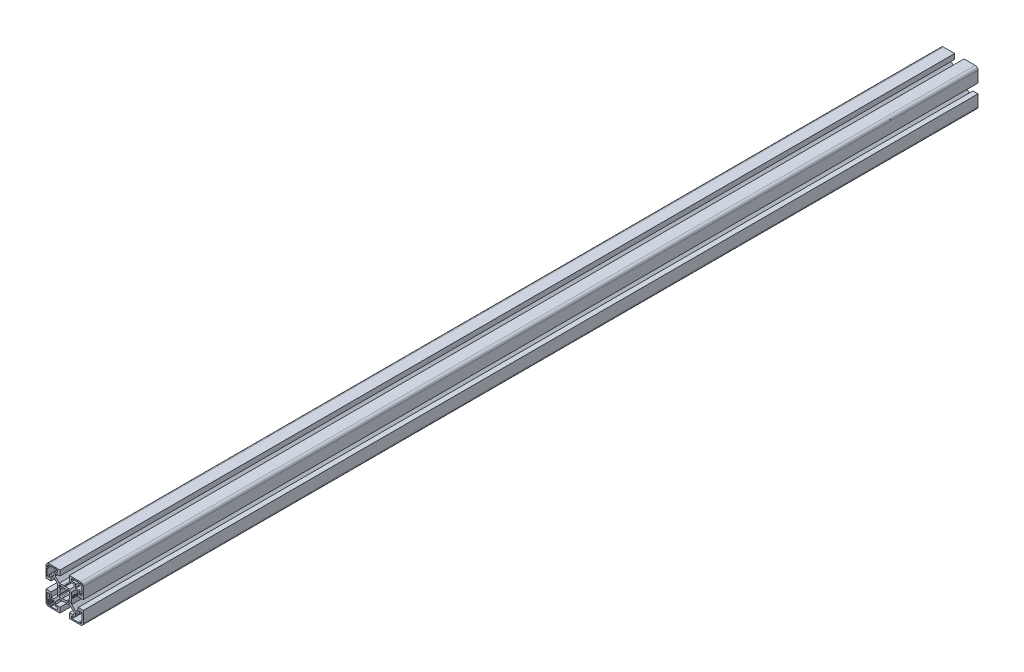
from build123d import *

# Parameters (mm, degrees)
BOSS_EXTRUDE1_DEPTH = 960


with BuildPart() as part:
    # Sketch1 → Boss-Extrude1 (new body)
    with BuildSketch(Plane.XY):
        with BuildLine():
            Line((-11.767766953, -10), (-14.5, -10))
            Line((-14.5, -10), (-14.5, -5))
            Line((-14.5, -5), (-20, -5))
            Line((-20, -5), (-20, -17))
            ThreePointArc((-20, -17), (-19.121320344, -19.121320344), (-17, -20))
            Line((-17, -20), (-5, -20))
            Line((-5, -20), (-5, -14.5))
            Line((-5, -14.5), (-10, -14.5))
            Line((-10, -14.5), (-10, -11.767766953))
            Line((-10, -11.767766953), (-5.732233047, -7.5))
            Line((-5.732233047, -7.5), (-0.653589838, -7.5))
            ThreePointArc((-0.653589838, -7.5), (-0.524180316, -7.482962913), (-0.403589838, -7.433012702))
            Line((-0.403589838, -7.433012702), (0, -7.2))
            Line((0, -7.2), (0.403589838, -7.433012702))
            ThreePointArc((0.403589838, -7.433012702), (0.653589838, -7.5), (0.903589838, -7.433012702))
            Line((0.903589838, -7.433012702), (1.218885629, -7.250976592))
            Line((1.218885629, -7.250976592), (2.5, -7.5))
            Line((2.5, -7.5), (5.732233047, -7.5))
            Line((5.732233047, -7.5), (10, -11.767766953))
            Line((10, -11.767766953), (10, -14.5))
            Line((10, -14.5), (5, -14.5))
            Line((5, -14.5), (5, -20))
            Line((5, -20), (17, -20))
            ThreePointArc((17, -20), (19.121320344, -19.121320344), (20, -17))
            Line((20, -17), (20, -5))
            Line((20, -5), (14.5, -5))
            Line((14.5, -5), (14.5, -10))
            Line((14.5, -10), (11.767766953, -10))
            Line((11.767766953, -10), (7.5, -5.732233047))
            Line((7.5, -5.732233047), (7.5, -0.653589838))
            ThreePointArc((7.5, -0.653589838), (7.482962913, -0.524180316), (7.433012702, -0.403589838))
            Line((7.433012702, -0.403589838), (7.2, 0))
            Line((7.2, 0), (7.433012702, 0.403589838))
            ThreePointArc((7.433012702, 0.403589838), (7.5, 0.653589838), (7.433012702, 0.903589838))
            Line((7.433012702, 0.903589838), (7.250976592, 1.218885629))
            Line((7.250976592, 1.218885629), (7.5, 2.5))
            Line((7.5, 2.5), (7.5, 5.732233047))
            Line((7.5, 5.732233047), (11.767766953, 10))
            Line((11.767766953, 10), (14.5, 10))
            Line((14.5, 10), (14.5, 5))
            Line((14.5, 5), (20, 5))
            Line((20, 5), (20, 17))
            ThreePointArc((20, 17), (19.121320344, 19.121320344), (17, 20))
            Line((17, 20), (5, 20))
            Line((5, 20), (5, 14.5))
            Line((5, 14.5), (10, 14.5))
            Line((10, 14.5), (10, 11.767766953))
            Line((10, 11.767766953), (5.732233047, 7.5))
            Line((5.732233047, 7.5), (0.653589838, 7.5))
            ThreePointArc((0.653589838, 7.5), (0.524180316, 7.482962913), (0.403589838, 7.433012702))
            Line((0.403589838, 7.433012702), (0, 7.2))
            Line((0, 7.2), (-0.403589838, 7.433012702))
            ThreePointArc((-0.403589838, 7.433012702), (-0.653589838, 7.5), (-0.903589838, 7.433012702))
            Line((-0.903589838, 7.433012702), (-1.218885629, 7.250976592))
            Line((-1.218885629, 7.250976592), (-2.5, 7.5))
            Line((-2.5, 7.5), (-5.732233047, 7.5))
            Line((-5.732233047, 7.5), (-10, 11.767766953))
            Line((-10, 11.767766953), (-10, 14.5))
            Line((-10, 14.5), (-5, 14.5))
            Line((-5, 14.5), (-5, 20))
            Line((-5, 20), (-17, 20))
            ThreePointArc((-17, 20), (-19.121320344, 19.121320344), (-20, 17))
            Line((-20, 17), (-20, 5))
            Line((-20, 5), (-14.5, 5))
            Line((-14.5, 5), (-14.5, 10))
            Line((-14.5, 10), (-11.767766953, 10))
            Line((-11.767766953, 10), (-7.5, 5.732233047))
            Line((-7.5, 5.732233047), (-7.5, 0.653589838))
            ThreePointArc((-7.5, 0.653589838), (-7.482962913, 0.524180316), (-7.433012702, 0.403589838))
            Line((-7.433012702, 0.403589838), (-7.2, 0))
            Line((-7.2, 0), (-7.433012702, -0.403589838))
            ThreePointArc((-7.433012702, -0.403589838), (-7.5, -0.653589838), (-7.433012702, -0.903589838))
            Line((-7.433012702, -0.903589838), (-7.250976592, -1.218885629))
            Line((-7.250976592, -1.218885629), (-7.5, -2.5))
            Line((-7.5, -2.5), (-7.5, -5.732233047))
            Line((-7.5, -5.732233047), (-11.767766953, -10))
        make_face()
        with BuildLine():
            Line((7.5, 16.5), (7.5, 18.2))
            ThreePointArc((7.5, 18.2), (7.646446609, 18.553553391), (8, 18.7))
            Line((8, 18.7), (14.8, 18.7))
            ThreePointArc((14.8, 18.7), (14.941421356, 18.641421356), (15, 18.5))
            Line((15, 18.5), (15, 18.2))
            ThreePointArc((15, 18.2), (15.058578644, 18.058578644), (15.2, 18))
            Line((15.2, 18), (16.4, 18))
            ThreePointArc((16.4, 18), (16.541421356, 18.058578644), (16.6, 18.2))
            Line((16.6, 18.2), (16.6, 18.5))
            ThreePointArc((16.6, 18.5), (16.658578644, 18.641421356), (16.8, 18.7))
            Line((16.8, 18.7), (17.3, 18.7))
            ThreePointArc((17.3, 18.7), (17.512132034, 18.612132034), (17.6, 18.4))
            Line((17.6, 18.4), (17.6, 17.9))
            ThreePointArc((17.6, 17.9), (17.687867966, 17.687867966), (17.9, 17.6))
            Line((17.9, 17.6), (18.4, 17.6))
            ThreePointArc((18.4, 17.6), (18.612132034, 17.512132034), (18.7, 17.3))
            Line((18.7, 17.3), (18.7, 16.8))
            ThreePointArc((18.7, 16.8), (18.641421356, 16.658578644), (18.5, 16.6))
            Line((18.5, 16.6), (18.2, 16.6))
            ThreePointArc((18.2, 16.6), (18.058578644, 16.541421356), (18, 16.4))
            Line((18, 16.4), (18, 15.2))
            ThreePointArc((18, 15.2), (18.058578644, 15.058578644), (18.2, 15))
            Line((18.2, 15), (18.5, 15))
            ThreePointArc((18.5, 15), (18.641421356, 14.941421356), (18.7, 14.8))
            Line((18.7, 14.8), (18.7, 8))
            ThreePointArc((18.7, 8), (18.553553391, 7.646446609), (18.2, 7.5))
            Line((18.2, 7.5), (16.5, 7.5))
            ThreePointArc((16.5, 7.5), (16.146446609, 7.646446609), (16, 8))
            Line((16, 8), (16, 10.2))
            ThreePointArc((16, 10.2), (15.619238816, 11.119238816), (14.7, 11.5))
            Line((14.7, 11.5), (12, 11.5))
            ThreePointArc((12, 11.5), (11.646446609, 11.646446609), (11.5, 12))
            Line((11.5, 12), (11.5, 14.7))
            ThreePointArc((11.5, 14.7), (11.119238816, 15.619238816), (10.2, 16))
            Line((10.2, 16), (8, 16))
            ThreePointArc((8, 16), (7.646446609, 16.146446609), (7.5, 16.5))
        make_face(mode=Mode.SUBTRACT)
        with BuildLine():
            Line((14.8, -18.7), (8, -18.7))
            ThreePointArc((8, -18.7), (7.646446609, -18.553553391), (7.5, -18.2))
            Line((7.5, -18.2), (7.5, -16.5))
            ThreePointArc((7.5, -16.5), (7.646446609, -16.146446609), (8, -16))
            Line((8, -16), (10.2, -16))
            ThreePointArc((10.2, -16), (11.119238816, -15.619238816), (11.5, -14.7))
            Line((11.5, -14.7), (11.5, -12))
            ThreePointArc((11.5, -12), (11.646446609, -11.646446609), (12, -11.5))
            Line((12, -11.5), (14.7, -11.5))
            ThreePointArc((14.7, -11.5), (15.619238816, -11.119238816), (16, -10.2))
            Line((16, -10.2), (16, -8))
            ThreePointArc((16, -8), (16.146446609, -7.646446609), (16.5, -7.5))
            Line((16.5, -7.5), (18.2, -7.5))
            ThreePointArc((18.2, -7.5), (18.553553391, -7.646446609), (18.7, -8))
            Line((18.7, -8), (18.7, -14.8))
            ThreePointArc((18.7, -14.8), (18.641421356, -14.941421356), (18.5, -15))
            Line((18.5, -15), (18.2, -15))
            ThreePointArc((18.2, -15), (18.058578644, -15.058578644), (18, -15.2))
            Line((18, -15.2), (18, -16.4))
            ThreePointArc((18, -16.4), (18.058578644, -16.541421356), (18.2, -16.6))
            Line((18.2, -16.6), (18.5, -16.6))
            ThreePointArc((18.5, -16.6), (18.641421356, -16.658578644), (18.7, -16.8))
            Line((18.7, -16.8), (18.7, -17.3))
            ThreePointArc((18.7, -17.3), (18.612132034, -17.512132034), (18.4, -17.6))
            Line((18.4, -17.6), (17.9, -17.6))
            ThreePointArc((17.9, -17.6), (17.687867966, -17.687867966), (17.6, -17.9))
            Line((17.6, -17.9), (17.6, -18.4))
            ThreePointArc((17.6, -18.4), (17.512132034, -18.612132034), (17.3, -18.7))
            Line((17.3, -18.7), (16.8, -18.7))
            ThreePointArc((16.8, -18.7), (16.658578644, -18.641421356), (16.6, -18.5))
            Line((16.6, -18.5), (16.6, -18.2))
            ThreePointArc((16.6, -18.2), (16.541421356, -18.058578644), (16.4, -18))
            Line((16.4, -18), (15.2, -18))
            ThreePointArc((15.2, -18), (15.058578644, -18.058578644), (15, -18.2))
            Line((15, -18.2), (15, -18.5))
            ThreePointArc((15, -18.5), (14.941421356, -18.641421356), (14.8, -18.7))
        make_face(mode=Mode.SUBTRACT)
        with BuildLine():
            Line((-18.7, 16.8), (-18.7, 17.3))
            ThreePointArc((-18.7, 17.3), (-18.612132034, 17.512132034), (-18.4, 17.6))
            Line((-18.4, 17.6), (-17.9, 17.6))
            ThreePointArc((-17.9, 17.6), (-17.687867966, 17.687867966), (-17.6, 17.9))
            Line((-17.6, 17.9), (-17.6, 18.4))
            ThreePointArc((-17.6, 18.4), (-17.512132034, 18.612132034), (-17.3, 18.7))
            Line((-17.3, 18.7), (-16.8, 18.7))
            ThreePointArc((-16.8, 18.7), (-16.658578644, 18.641421356), (-16.6, 18.5))
            Line((-16.6, 18.5), (-16.6, 18.2))
            ThreePointArc((-16.6, 18.2), (-16.541421356, 18.058578644), (-16.4, 18))
            Line((-16.4, 18), (-15.2, 18))
            ThreePointArc((-15.2, 18), (-15.058578644, 18.058578644), (-15, 18.2))
            Line((-15, 18.2), (-15, 18.5))
            ThreePointArc((-15, 18.5), (-14.941421356, 18.641421356), (-14.8, 18.7))
            Line((-14.8, 18.7), (-8, 18.7))
            ThreePointArc((-8, 18.7), (-7.646446609, 18.553553391), (-7.5, 18.2))
            Line((-7.5, 18.2), (-7.5, 16.5))
            ThreePointArc((-7.5, 16.5), (-7.646446609, 16.146446609), (-8, 16))
            Line((-8, 16), (-10.2, 16))
            ThreePointArc((-10.2, 16), (-11.119238816, 15.619238816), (-11.5, 14.7))
            Line((-11.5, 14.7), (-11.5, 12))
            ThreePointArc((-11.5, 12), (-11.646446609, 11.646446609), (-12, 11.5))
            Line((-12, 11.5), (-14.7, 11.5))
            ThreePointArc((-14.7, 11.5), (-15.619238816, 11.119238816), (-16, 10.2))
            Line((-16, 10.2), (-16, 8))
            ThreePointArc((-16, 8), (-16.146446609, 7.646446609), (-16.5, 7.5))
            Line((-16.5, 7.5), (-18.2, 7.5))
            ThreePointArc((-18.2, 7.5), (-18.553553391, 7.646446609), (-18.7, 8))
            Line((-18.7, 8), (-18.7, 14.8))
            ThreePointArc((-18.7, 14.8), (-18.641421356, 14.941421356), (-18.5, 15))
            Line((-18.5, 15), (-18.2, 15))
            ThreePointArc((-18.2, 15), (-18.058578644, 15.058578644), (-18, 15.2))
            Line((-18, 15.2), (-18, 16.4))
            ThreePointArc((-18, 16.4), (-18.058578644, 16.541421356), (-18.2, 16.6))
            Line((-18.2, 16.6), (-18.5, 16.6))
            ThreePointArc((-18.5, 16.6), (-18.641421356, 16.658578644), (-18.7, 16.8))
        make_face(mode=Mode.SUBTRACT)
        with BuildLine():
            Line((-18.7, -14.8), (-18.7, -8))
            ThreePointArc((-18.7, -8), (-18.553553391, -7.646446609), (-18.2, -7.5))
            Line((-18.2, -7.5), (-16.5, -7.5))
            ThreePointArc((-16.5, -7.5), (-16.146446609, -7.646446609), (-16, -8))
            Line((-16, -8), (-16, -10.2))
            ThreePointArc((-16, -10.2), (-15.619238816, -11.119238816), (-14.7, -11.5))
            Line((-14.7, -11.5), (-12, -11.5))
            ThreePointArc((-12, -11.5), (-11.646446609, -11.646446609), (-11.5, -12))
            Line((-11.5, -12), (-11.5, -14.7))
            ThreePointArc((-11.5, -14.7), (-11.119238816, -15.619238816), (-10.2, -16))
            Line((-10.2, -16), (-8, -16))
            ThreePointArc((-8, -16), (-7.646446609, -16.146446609), (-7.5, -16.5))
            Line((-7.5, -16.5), (-7.5, -18.2))
            ThreePointArc((-7.5, -18.2), (-7.646446609, -18.553553391), (-8, -18.7))
            Line((-8, -18.7), (-14.8, -18.7))
            ThreePointArc((-14.8, -18.7), (-14.941421356, -18.641421356), (-15, -18.5))
            Line((-15, -18.5), (-15, -18.2))
            ThreePointArc((-15, -18.2), (-15.058578644, -18.058578644), (-15.2, -18))
            Line((-15.2, -18), (-16.4, -18))
            ThreePointArc((-16.4, -18), (-16.541421356, -18.058578644), (-16.6, -18.2))
            Line((-16.6, -18.2), (-16.6, -18.5))
            ThreePointArc((-16.6, -18.5), (-16.658578644, -18.641421356), (-16.8, -18.7))
            Line((-16.8, -18.7), (-17.3, -18.7))
            ThreePointArc((-17.3, -18.7), (-17.512132034, -18.612132034), (-17.6, -18.4))
            Line((-17.6, -18.4), (-17.6, -17.9))
            ThreePointArc((-17.6, -17.9), (-17.687867966, -17.687867966), (-17.9, -17.6))
            Line((-17.9, -17.6), (-18.4, -17.6))
            ThreePointArc((-18.4, -17.6), (-18.612132034, -17.512132034), (-18.7, -17.3))
            Line((-18.7, -17.3), (-18.7, -16.8))
            ThreePointArc((-18.7, -16.8), (-18.641421356, -16.658578644), (-18.5, -16.6))
            Line((-18.5, -16.6), (-18.2, -16.6))
            ThreePointArc((-18.2, -16.6), (-18.058578644, -16.541421356), (-18, -16.4))
            Line((-18, -16.4), (-18, -15.2))
            ThreePointArc((-18, -15.2), (-18.058578644, -15.058578644), (-18.2, -15))
            Line((-18.2, -15), (-18.5, -15))
            ThreePointArc((-18.5, -15), (-18.641421356, -14.941421356), (-18.7, -14.8))
        make_face(mode=Mode.SUBTRACT)
        with BuildLine():
            Line((-6, 3.490686899), (-6, 5))
            ThreePointArc((-6, 5), (-5.707106781, 5.707106781), (-5, 6))
            Line((-5, 6), (-3.490686899, 6))
            ThreePointArc((-3.490686899, 6), (-3.233167862, 5.92858365), (-3.049213103, 5.734735781))
            Line((-3.049213103, 5.734735781), (-2.689236216, 5.057717724))
            ThreePointArc((-2.689236216, 5.057717724), (-2.414618721, 4.821116073), (-2.052304818, 4.832240157))
            ThreePointArc((-2.052304818, 4.832240157), (0, 5.25), (2.052304818, 4.832240157))
            ThreePointArc((2.052304818, 4.832240157), (2.414618721, 4.821116073), (2.689236216, 5.057717724))
            Line((2.689236216, 5.057717724), (3.049213103, 5.734735781))
            ThreePointArc((3.049213103, 5.734735781), (3.233167862, 5.92858365), (3.490686899, 6))
            Line((3.490686899, 6), (5, 6))
            ThreePointArc((5, 6), (5.707106781, 5.707106781), (6, 5))
            Line((6, 5), (6, 3.490686899))
            ThreePointArc((6, 3.490686899), (5.92858365, 3.233167862), (5.734735781, 3.049213103))
            Line((5.734735781, 3.049213103), (5.057717724, 2.689236216))
            ThreePointArc((5.057717724, 2.689236216), (4.821116073, 2.414618721), (4.832240157, 2.052304818))
            ThreePointArc((4.832240157, 2.052304818), (5.25, 0), (4.832240157, -2.052304818))
            ThreePointArc((4.832240157, -2.052304818), (4.821116073, -2.414618721), (5.057717724, -2.689236216))
            Line((5.057717724, -2.689236216), (5.734735781, -3.049213103))
            ThreePointArc((5.734735781, -3.049213103), (5.92858365, -3.233167862), (6, -3.490686899))
            Line((6, -3.490686899), (6, -5))
            ThreePointArc((6, -5), (5.707106781, -5.707106781), (5, -6))
            Line((5, -6), (3.490686899, -6))
            ThreePointArc((3.490686899, -6), (3.233167862, -5.92858365), (3.049213103, -5.734735781))
            Line((3.049213103, -5.734735781), (2.689236216, -5.057717724))
            ThreePointArc((2.689236216, -5.057717724), (2.414618721, -4.821116073), (2.052304818, -4.832240157))
            ThreePointArc((2.052304818, -4.832240157), (0, -5.25), (-2.052304818, -4.832240157))
            ThreePointArc((-2.052304818, -4.832240157), (-2.414618721, -4.821116073), (-2.689236216, -5.057717724))
            Line((-2.689236216, -5.057717724), (-3.049213103, -5.734735781))
            ThreePointArc((-3.049213103, -5.734735781), (-3.233167862, -5.92858365), (-3.490686899, -6))
            Line((-3.490686899, -6), (-5, -6))
            ThreePointArc((-5, -6), (-5.707106781, -5.707106781), (-6, -5))
            Line((-6, -5), (-6, -3.490686899))
            ThreePointArc((-6, -3.490686899), (-5.92858365, -3.233167862), (-5.734735781, -3.049213103))
            Line((-5.734735781, -3.049213103), (-5.057717724, -2.689236216))
            ThreePointArc((-5.057717724, -2.689236216), (-4.821116073, -2.414618721), (-4.832240157, -2.052304818))
            ThreePointArc((-4.832240157, -2.052304818), (-5.25, 0), (-4.832240157, 2.052304818))
            ThreePointArc((-4.832240157, 2.052304818), (-4.821116073, 2.414618721), (-5.057717724, 2.689236216))
            Line((-5.057717724, 2.689236216), (-5.734735781, 3.049213103))
            ThreePointArc((-5.734735781, 3.049213103), (-5.92858365, 3.233167862), (-6, 3.490686899))
        make_face(mode=Mode.SUBTRACT)
    extrude(amount=-BOSS_EXTRUDE1_DEPTH)


solid = part.part
